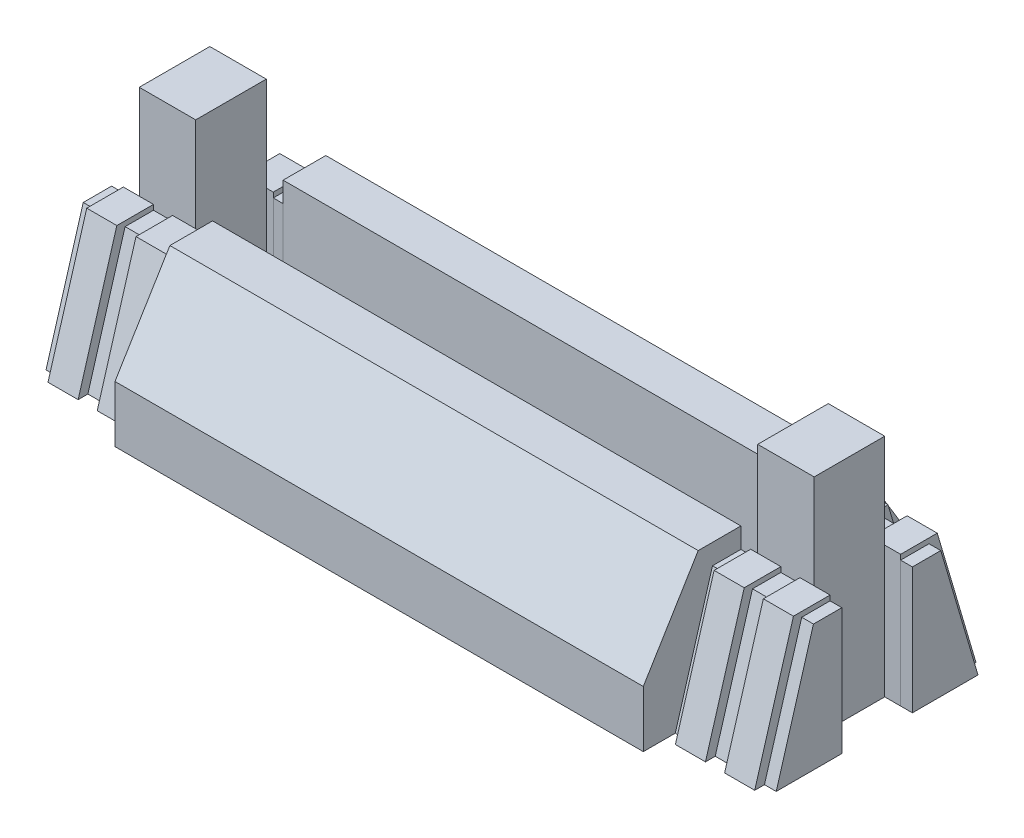
from build123d import *

# Parameters (mm, degrees)
EXTRUDE_1_DEPTH   = 41.66
EXTRUDE_1_2_DEPTH = 41.66
EXTRUDE_2_DEPTH   = 106.69
EXTRUDE_START     = 148.35
EXTRUDE_3_DEPTH   = 67.71
EXTRUDE_START_2   = 174.4
EXTRUDE_4_DEPTH   = 106.69
EXTRUDE_START_3   = 322.75
EXTRUDE_5_DEPTH   = 34.9
EXTRUDE_6_DEPTH   = 1871.94
EXTRUDE_START_4   = 2229.59
EXTRUDE_9_DEPTH   = 34.9
EXTRUDE_START_5   = 2222.83
EXTRUDE_10_DEPTH  = 106.69
EXTRUDE_START_6   = 2371.18
EXTRUDE_11_DEPTH  = 67.71
EXTRUDE_START_7   = 2397.23
EXTRUDE_12_DEPTH  = 106.69
EXTRUDE_START_8   = 2545.58
EXTRUDE_13_DEPTH  = 41.66
SKETCH_4_W        = 200
SKETCH_4_H        = 250
EXTRUDE_14_DEPTH  = 800


with BuildPart() as part:
    # 草图1 → 凸台-拉伸1 (new body)
    with BuildSketch(Plane(origin=(0, 0, 0), x_dir=(0, 0, -1), z_dir=(1, 0, 0))):
        Polygon((0, 0), (-232.46, 0), (-100.52, 447.79), (0, 447.79), align=None)
    extrude(amount=EXTRUDE_1_DEPTH)

    # 草图2 → 凸台-拉伸2 (add)
    with BuildSketch(Plane(origin=(41.66, 0, 0), x_dir=(0, 0, -1), z_dir=(1, 0, 0))):
        Polygon((0, 465.74), (-129.79, 465.74), (-267.018914447, 0), (0, 0), align=None)
        Polygon((250, 0), (250, 465.74), (379.79, 465.74), (517.018914447, 0), align=None)
    extrude(amount=EXTRUDE_2_DEPTH)


with BuildPart() as body_2:
    # 草图1 → Extrude 1 2 (new body)
    with BuildSketch(Plane(origin=(0, 0, 0), x_dir=(0, 0, -1), z_dir=(1, 0, 0))):
        Polygon((250, 447.79), (250, 0), (482.46, 0), (350.52, 447.79), align=None)
    extrude(amount=EXTRUDE_1_2_DEPTH)


with BuildPart() as extrude_2_piece_1:
    # of the separate pieces the step leaves, piece 1, a body of its own (extrude_2_pieces)
    add(part.part.solids().sort_by_distance((0, 0, 0))[0])

    # 草图1<2> → 凸台-拉伸3 (add)
    with BuildSketch(Plane(origin=(0, 0, 0), x_dir=(0, 0, -1), z_dir=(1, 0, 0)).offset(EXTRUDE_START)):
        Polygon((0, 0), (-232.46, 0), (-100.52, 447.79), (0, 447.79), align=None)
        Polygon((250, 447.79), (250, 0), (482.46, 0), (350.52, 447.79), align=None)
    extrude(amount=EXTRUDE_3_DEPTH)


with BuildPart() as extrude_2_piece_2:
    # of the separate pieces the step leaves, piece 2, a body of its own (extrude_2_pieces)
    add(part.part.solids().sort_by_distance((41.66, 0, -250))[0])



with BuildPart() as extrude_3_piece_1:
    # of the separate pieces the step leaves, piece 1, a body of its own (extrude_3_pieces)
    add(extrude_2_piece_1.part.solids().sort_by_distance((0, 0, 0))[0])

    # 草图2<2> → 凸台-拉伸4 (add)
    with BuildSketch(Plane(origin=(41.66, 0, 0), x_dir=(0, 0, -1), z_dir=(1, 0, 0)).offset(EXTRUDE_START_2)):
        Polygon((0, 465.74), (-129.79, 465.74), (-267.018914447, 0), (0, 0), align=None)
        Polygon((250, 0), (250, 465.74), (379.79, 465.74), (517.018914447, 0), align=None)
    extrude(amount=EXTRUDE_4_DEPTH)


with BuildPart() as extrude_3_piece_2:
    # of the separate pieces the step leaves, piece 2, a body of its own (extrude_3_pieces)
    add(extrude_2_piece_1.part.solids().sort_by_distance((148.35, 447.79, -250))[0])


with BuildPart() as extrude_4_piece_1:
    # of the separate pieces the step leaves, piece 1, a body of its own (extrude_4_pieces)
    add(extrude_3_piece_1.part.solids().sort_by_distance((0, 0, 0))[0])

    # 草图1<3> → 凸台-拉伸5 (add)
    with BuildSketch(Plane(origin=(0, 0, 0), x_dir=(0, 0, -1), z_dir=(1, 0, 0)).offset(EXTRUDE_START_3)):
        Polygon((0, 0), (-232.46, 0), (-100.52, 447.79), (0, 447.79), align=None)
        Polygon((250, 447.79), (250, 0), (482.46, 0), (350.52, 447.79), align=None)
    extrude(amount=EXTRUDE_5_DEPTH)


with BuildPart() as extrude_4_piece_2:
    # of the separate pieces the step leaves, piece 2, a body of its own (extrude_4_pieces)
    add(extrude_3_piece_1.part.solids().sort_by_distance((216.06, 0, -250))[0])


with BuildPart() as extrude_5_piece_1:
    # of the separate pieces the step leaves, piece 1, a body of its own (extrude_5_pieces)
    add(extrude_4_piece_1.part.solids().sort_by_distance((0, 0, 0))[0])

    # 草图3 → 凸台-拉伸6 (add)
    with BuildSketch(Plane(origin=(357.65, 0, 0), x_dir=(0, 0, -1), z_dir=(1, 0, 0))):
        Polygon((0, 0), (0, 519.76), (-151.24, 519.76), (-345.72416388, 200), (-345.72416388, 0), align=None)
        Polygon((595.72416388, 0), (250, 0), (250, 519.76), (401.24, 519.76), (595.72416388, 200), align=None)
    extrude(amount=EXTRUDE_6_DEPTH)


with BuildPart() as extrude_5_piece_2:
    # of the separate pieces the step leaves, piece 2, a body of its own (extrude_5_pieces)
    add(extrude_4_piece_1.part.solids().sort_by_distance((322.75, 447.79, -250))[0])


with BuildPart() as extrude_6_piece_1:
    # of the separate pieces the step leaves, piece 1, a body of its own (extrude_6_pieces)
    add(extrude_5_piece_1.part.solids().sort_by_distance((0, 0, 0))[0])

    # 草图1<4> → 凸台-拉伸9 (add)
    with BuildSketch(Plane(origin=(0, 0, 0), x_dir=(0, 0, -1), z_dir=(1, 0, 0)).offset(EXTRUDE_START_4)):
        Polygon((0, 0), (-232.46, 0), (-100.52, 447.79), (0, 447.79), align=None)
        Polygon((250, 447.79), (250, 0), (482.46, 0), (350.52, 447.79), align=None)
    extrude(amount=EXTRUDE_9_DEPTH)


with BuildPart() as extrude_6_piece_2:
    # of the separate pieces the step leaves, piece 2, a body of its own (extrude_6_pieces)
    add(extrude_5_piece_1.part.solids().sort_by_distance((357.65, 0, -595.72416388))[0])


with BuildPart() as extrude_9_piece_1:
    # of the separate pieces the step leaves, piece 1, a body of its own (extrude_9_pieces)
    add(extrude_6_piece_1.part.solids().sort_by_distance((0, 0, 0))[0])

    # 草图2<8> → 凸台-拉伸10 (add)
    with BuildSketch(Plane(origin=(41.66, 0, 0), x_dir=(0, 0, -1), z_dir=(1, 0, 0)).offset(EXTRUDE_START_5)):
        Polygon((0, 465.74), (-129.79, 465.74), (-267.018914447, 0), (0, 0), align=None)
        Polygon((250, 0), (250, 465.74), (379.79, 465.74), (517.018914447, 0), align=None)
    extrude(amount=EXTRUDE_10_DEPTH)


with BuildPart() as extrude_9_piece_2:
    # of the separate pieces the step leaves, piece 2, a body of its own (extrude_9_pieces)
    add(extrude_6_piece_1.part.solids().sort_by_distance((2229.59, 447.79, -250))[0])


with BuildPart() as extrude_10_piece_1:
    # of the separate pieces the step leaves, piece 1, a body of its own (extrude_10_pieces)
    add(extrude_9_piece_1.part.solids().sort_by_distance((0, 0, 0))[0])

    # 草图1<5> → 凸台-拉伸11 (add)
    with BuildSketch(Plane(origin=(0, 0, 0), x_dir=(0, 0, -1), z_dir=(1, 0, 0)).offset(EXTRUDE_START_6)):
        Polygon((0, 0), (-232.46, 0), (-100.52, 447.79), (0, 447.79), align=None)
        Polygon((250, 447.79), (250, 0), (482.46, 0), (350.52, 447.79), align=None)
    extrude(amount=EXTRUDE_11_DEPTH)


with BuildPart() as extrude_10_piece_2:
    # of the separate pieces the step leaves, piece 2, a body of its own (extrude_10_pieces)
    add(extrude_9_piece_1.part.solids().sort_by_distance((2264.49, 0, -250))[0])


with BuildPart() as extrude_11_piece_1:
    # of the separate pieces the step leaves, piece 1, a body of its own (extrude_11_pieces)
    add(extrude_10_piece_1.part.solids().sort_by_distance((0, 0, 0))[0])

    # 草图2<10> → 凸台-拉伸12 (add)
    with BuildSketch(Plane(origin=(41.66, 0, 0), x_dir=(0, 0, -1), z_dir=(1, 0, 0)).offset(EXTRUDE_START_7)):
        Polygon((0, 465.74), (-129.79, 465.74), (-267.018914447, 0), (0, 0), align=None)
        Polygon((250, 0), (250, 465.74), (379.79, 465.74), (517.018914447, 0), align=None)
    extrude(amount=EXTRUDE_12_DEPTH)


with BuildPart() as extrude_11_piece_2:
    # of the separate pieces the step leaves, piece 2, a body of its own (extrude_11_pieces)
    add(extrude_10_piece_1.part.solids().sort_by_distance((2371.18, 447.79, -250))[0])


with BuildPart() as extrude_12_piece_1:
    # of the separate pieces the step leaves, piece 1, a body of its own (extrude_12_pieces)
    add(extrude_11_piece_1.part.solids().sort_by_distance((0, 0, 0))[0])

    # 草图1<6> → 凸台-拉伸13 (add)
    with BuildSketch(Plane(origin=(0, 0, 0), x_dir=(0, 0, -1), z_dir=(1, 0, 0)).offset(EXTRUDE_START_8)):
        Polygon((0, 0), (-232.46, 0), (-100.52, 447.79), (0, 447.79), align=None)
        Polygon((250, 447.79), (250, 0), (482.46, 0), (350.52, 447.79), align=None)
    extrude(amount=EXTRUDE_13_DEPTH)


with BuildPart() as extrude_12_piece_2:
    # of the separate pieces the step leaves, piece 2, a body of its own (extrude_12_pieces)
    add(extrude_11_piece_1.part.solids().sort_by_distance((2438.89, 0, -250))[0])


with BuildPart() as extrude_13_piece_1:
    # of the separate pieces the step leaves, piece 1, a body of its own (extrude_13_pieces)
    add(extrude_12_piece_1.part.solids().sort_by_distance((0, 0, 0))[0])


with BuildPart() as extrude_13_piece_2:
    # of the separate pieces the step leaves, piece 2, a body of its own (extrude_13_pieces)
    add(extrude_12_piece_1.part.solids().sort_by_distance((2545.58, 447.79, -250))[0])


with BuildPart() as extrude_2_piece_2_1:
    add(extrude_2_piece_2.part)

    add(extrude_3_piece_2.part)  # 凸台-拉伸14 merges 凸台-拉伸3 piece 2

    add(extrude_4_piece_2.part)  # 凸台-拉伸14 merges 凸台-拉伸4 piece 2

    add(extrude_10_piece_2.part)  # 凸台-拉伸14 merges 凸台-拉伸10 piece 2

    add(extrude_11_piece_2.part)  # 凸台-拉伸14 merges 凸台-拉伸11 piece 2

    add(extrude_12_piece_2.part)  # 凸台-拉伸14 merges 凸台-拉伸12 piece 2

    add(extrude_13_piece_1.part)  # 凸台-拉伸14 merges 凸台-拉伸13 piece 1
    # 草图4 → 凸台-拉伸14 (add)
    with BuildSketch(Plane(origin=(0, 0, 0), x_dir=(1, 0, 0), z_dir=(0, 1, 0))):
        with Locations((198, 125)):
            Rectangle(SKETCH_4_W, SKETCH_4_H)
        with Locations((2389.24, 125)):
            Rectangle(SKETCH_4_W, SKETCH_4_H)
    extrude(amount=EXTRUDE_14_DEPTH)


solid = Compound([body_2.part, extrude_5_piece_2.part, extrude_6_piece_2.part, extrude_9_piece_2.part, extrude_13_piece_2.part, extrude_2_piece_2_1.part])
